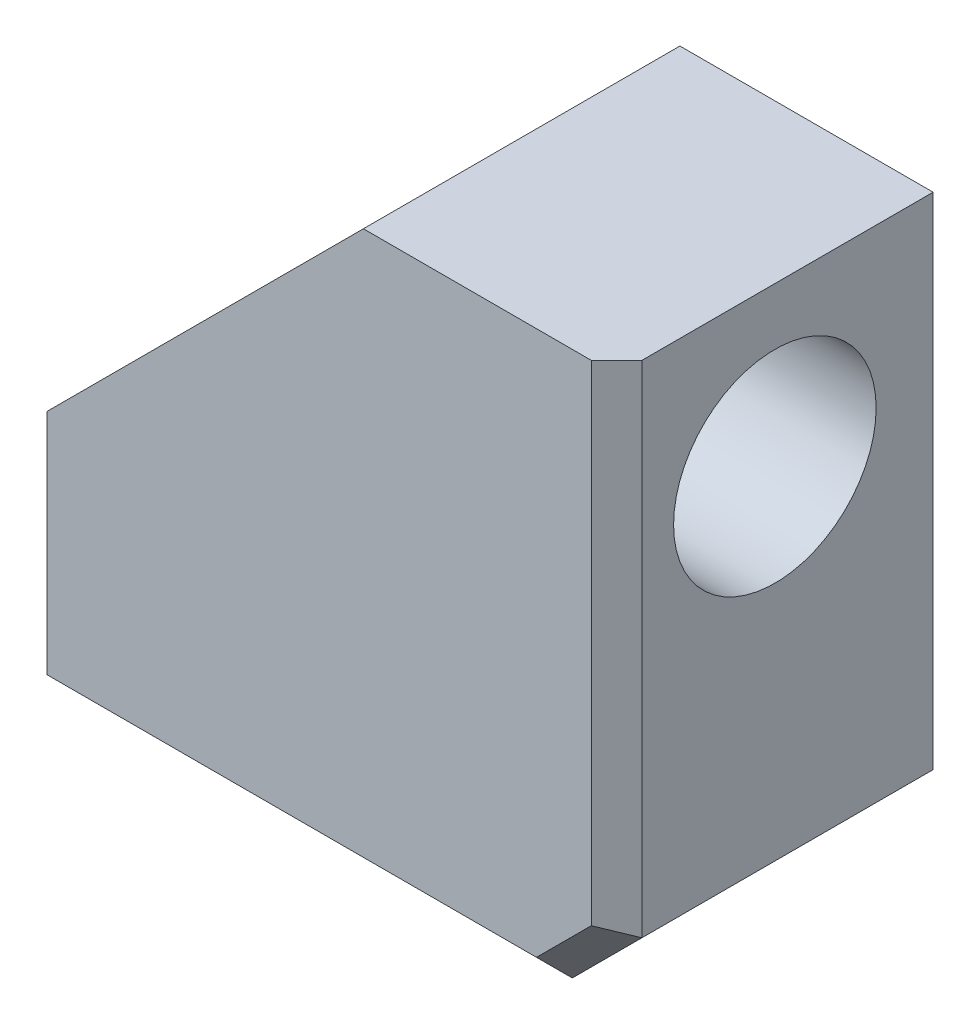
from build123d import *

# Parameters (mm, degrees)
SKETCH1_W           = 9
SKETCH1_H           = 9
BOSS_EXTRUDE1_DEPTH = 5
SKETCH2_R           = 1.6
CUT_EXTRUDE1_DEPTH  = 4.5
SKETCH3_R           = 1.6
CUT_EXTRUDE2_DEPTH  = 4.5
SKETCH4_R           = 1.6
CUT_EXTRUDE3_DEPTH  = 4.5
CHAMFER1_SIZE       = 1.1
CHAMFER2_SIZE       = 5
CHAMFER3_SIZE       = 0.4


with BuildPart() as part:
    # Sketch1 → Boss-Extrude1 (new body)
    with BuildSketch(Plane.XY):
        Rectangle(SKETCH1_W, SKETCH1_H)
    extrude(amount=BOSS_EXTRUDE1_DEPTH)

    # Sketch2 → Cut-Extrude1 (cut)
    with BuildSketch(Plane(origin=(0, 0, 0), x_dir=(-1, 0, 0), z_dir=(0, 0, -1))):
        with Locations((-2, -2)):
            Circle(SKETCH2_R)
    extrude(amount=-CUT_EXTRUDE1_DEPTH, mode=Mode.SUBTRACT)

    # Sketch3 → Cut-Extrude2 (cut)
    with BuildSketch(Plane(origin=(4.5, 0, 0), x_dir=(0, 0, -1), z_dir=(1, 0, 0))):
        with Locations((-2.5, 2)):
            Circle(SKETCH3_R)
    extrude(amount=-CUT_EXTRUDE2_DEPTH, mode=Mode.SUBTRACT)

    # Sketch4 → Cut-Extrude3 (cut)
    with BuildSketch(Plane.XZ.offset(4.5)):
        with Locations((-2, 2.5)):
            Circle(SKETCH4_R)
    extrude(amount=-CUT_EXTRUDE3_DEPTH, mode=Mode.SUBTRACT)

    # Chamfer1
    chamfer1_edges = [part.edges().sort_by_distance(p)[0] for p in [
        (4.5, -4.5, 2.5),
    ]]
    chamfer(chamfer1_edges, length=CHAMFER1_SIZE)

    # Chamfer2
    chamfer2_edges = [part.edges().sort_by_distance(p)[0] for p in [
        (-4.5, 4.5, 2.5),
    ]]
    chamfer(chamfer2_edges, length=CHAMFER2_SIZE)

    # Chamfer3
    chamfer3_edges = [part.edges().sort_by_distance(p)[0] for p in [
        (4.5, 0.55, 5),
        (3.95, -3.95, 5),
        (-0.55, -4.5, 5),
    ]]
    chamfer(chamfer3_edges, length=CHAMFER3_SIZE)


solid = part.part
